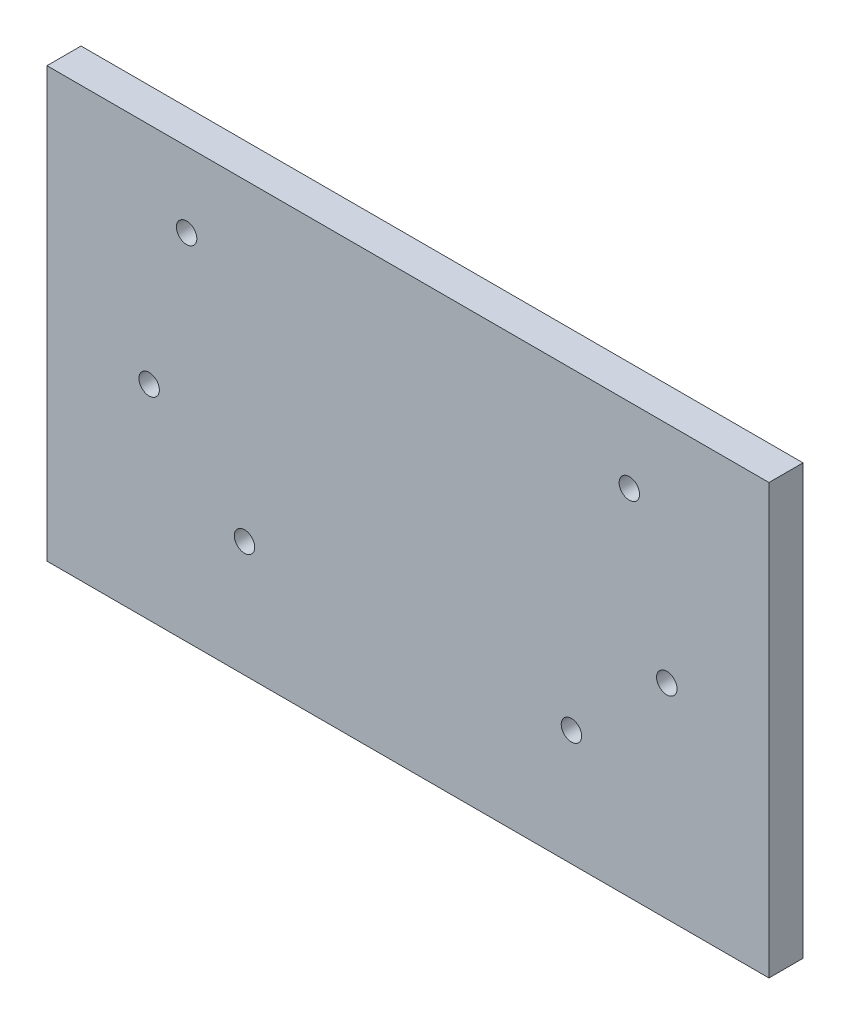
from build123d import *

# Parameters (mm, degrees)
SKETCH1_W           = 106
SKETCH1_H           = 63
BOSS_EXTRUDE1_DEPTH = 5
SKETCH2_R           = 1.5
CUT_EXTRUDE2_DEPTH  = 6


with BuildPart() as part:
    # Sketch1 → Boss-Extrude1 (new body)
    with BuildSketch(Plane.XY):
        Rectangle(SKETCH1_W, SKETCH1_H)
    extrude(amount=BOSS_EXTRUDE1_DEPTH)

    # Sketch2 → Cut-Extrude2 (cut, through all)
    with BuildSketch(Plane.XY):
        with Locations((-24, -14.5)):
            Circle(SKETCH2_R)
        with Locations((24, -14.5)):
            Circle(SKETCH2_R)
        with Locations((-38, -1.5)):
            Circle(SKETCH2_R)
        with Locations((38, -1.5)):
            Circle(SKETCH2_R)
        with Locations((-32.5, 20.5)):
            Circle(SKETCH2_R)
        with Locations((32.5, 20.5)):
            Circle(SKETCH2_R)
    extrude(amount=CUT_EXTRUDE2_DEPTH, mode=Mode.SUBTRACT)


solid = part.part
